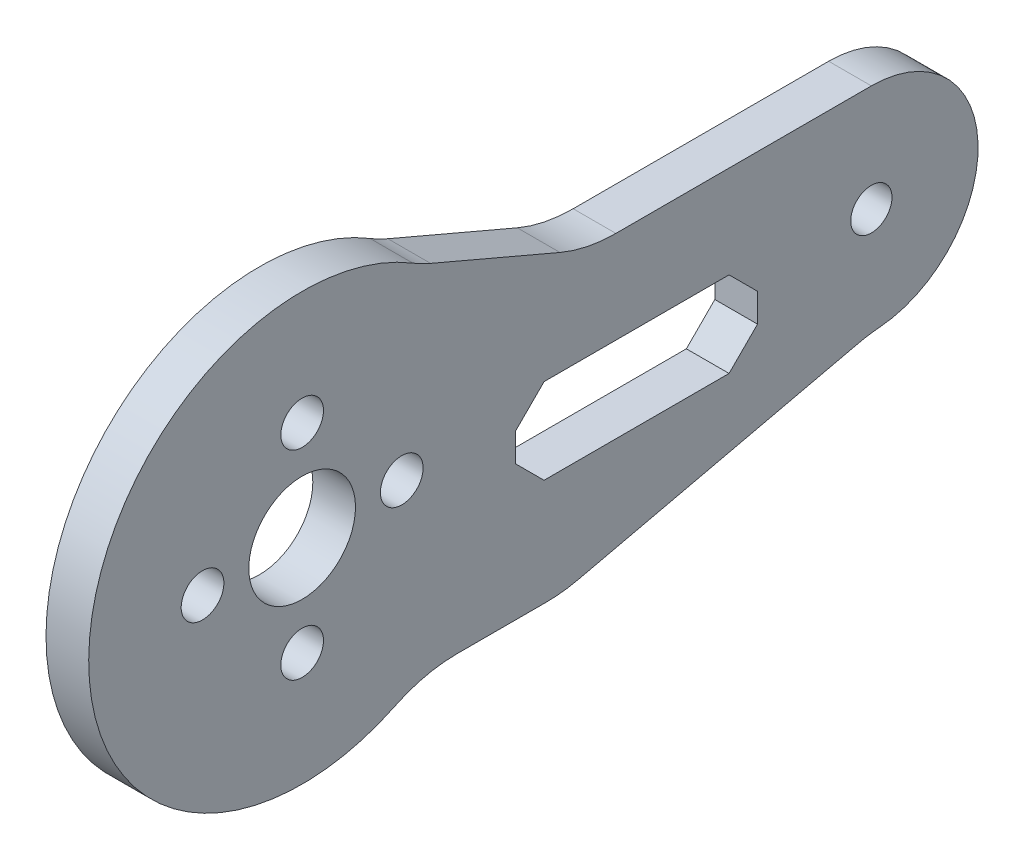
from build123d import *

# Parameters (mm, degrees)
SKETCH1_R           = 7.5
SKETCH1_R_2         = 1.45
SKETCH1_R_3         = 1.5
SKETCH1_R_4         = 3.75
BOSS_EXTRUDE1_DEPTH = 1.5
FILLET1_R           = 10
CUT_EXTRUDE1_DEPTH  = 3


with BuildPart() as part:
    # Sketch1 → Boss-Extrude1 (new body, symmetric)
    with BuildSketch(Plane(origin=(0, 0, 0), x_dir=(0, 0, -1), z_dir=(1, 0, 0))):
        with BuildLine():
            Line((18.291561976, -12.5), (40, -7.5))
            ThreePointArc((40, -7.5), (32.5, 0), (40, 7.5))
            Line((40, 7.5), (20, 7.5))
            Line((20, 7.5), (8.291561976, 12.5))
            ThreePointArc((8.291561976, 12.5), (13.216910184, 7.093185827), (15, 0))
            ThreePointArc((15, 0), (13.216910184, -7.093185827), (8.291561976, -12.5))
            Line((8.291561976, -12.5), (18.291561976, -12.5))
        make_face()
        with Locations((40, 0)):
            Circle(SKETCH1_R)
        with Locations((40, 0)):
            Circle(SKETCH1_R_2, mode=Mode.SUBTRACT)
        with BuildLine():
            ThreePointArc((8.291561976, 12.5), (-15, 0), (8.291561976, -12.5))
            ThreePointArc((8.291561976, -12.5), (13.216910184, -7.093185827), (15, 0))
            ThreePointArc((15, 0), (13.216910184, 7.093185827), (8.291561976, 12.5))
        make_face()
        with Locations((0, -7)):
            Circle(SKETCH1_R_3, mode=Mode.SUBTRACT)
        with Locations((-7, 0)):
            Circle(SKETCH1_R_3, mode=Mode.SUBTRACT)
        Circle(SKETCH1_R_4, mode=Mode.SUBTRACT)
        with Locations((0, 7)):
            Circle(SKETCH1_R_3, mode=Mode.SUBTRACT)
        with Locations((7, 0)):
            Circle(SKETCH1_R_3, mode=Mode.SUBTRACT)
    extrude(amount=BOSS_EXTRUDE1_DEPTH, both=True)

    # Fillet1
    fillet1_edges = [part.edges().sort_by_distance(p)[0] for p in [
        (0, -12.5, -18.291561976),
        (0, -12.5, -8.291561976),
        (0, 12.5, -8.291561976),
        (0, 7.5, -20),
        (0, -7.5, -40),
    ]]
    fillet(fillet1_edges, radius=FILLET1_R)

    # Sketch2 → Cut-Extrude1 (cut)
    with BuildSketch(Plane(origin=(1.5, 0, 0), x_dir=(0, 0, -1), z_dir=(1, 0, 0))):
        Polygon((17, 1), (30, 1), (32, -1), (32, -3), (30, -5), (17, -5), (15, -3), (15, -1), align=None)
    extrude(amount=-CUT_EXTRUDE1_DEPTH, mode=Mode.SUBTRACT)


solid = part.part
